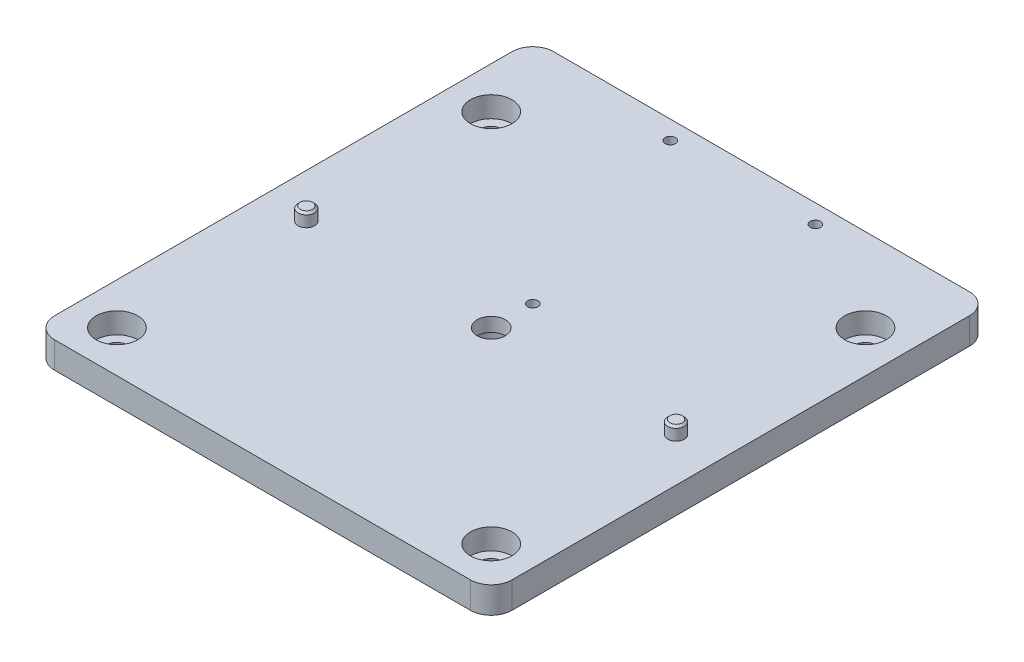
from build123d import *

# Parameters (mm, degrees)
BOSS_EXTRUDE1_DEPTH                              = 6.35
CBORE_FOR_1_4_SOCKET_HEAD_CAP_SCREW1_D           = 6.7564
CBORE_FOR_1_4_SOCKET_HEAD_CAP_SCREW1_CBORE_D     = 11.1125
CBORE_FOR_1_4_SOCKET_HEAD_CAP_SCREW1_CBORE_DEPTH = 2.999994
CBORE_FOR_M5_SHCS1_D                             = 5.5
CBORE_FOR_M5_SHCS1_DEPTH                         = 11.59
CBORE_FOR_M5_SHCS1_CBORE_D                       = 10
CBORE_FOR_M5_SHCS1_CBORE_DEPTH                   = 5
CBORE_FOR_M5_SHCS1_TIP                           = 1.652366702
F_1_8_0_125_PRESS_DOWEL_HOLE1_D                  = 3.96875
SKETCH12_W                                       = 110
SKETCH12_H                                       = 6.35
BOSS_EXTRUDE3_DEPTH                              = 10
FILLET1_R                                        = 5
M3X0_5_TAPPED_HOLE1_D                            = 2.5
SKETCH13_R                                       = 1.984375
BOSS_EXTRUDE4_DEPTH                              = 9.525
BOSS_EXTRUDE4_2_DEPTH                            = 9.525
CHAMFER1_SIZE                                    = 0.5
CHAMFER2_SIZE                                    = 0.5


with BuildPart() as part:
    # Sketch1 → Boss-Extrude1 (new body)
    with BuildSketch(Plane(origin=(0, 0, 0), x_dir=(1, 0, 0), z_dir=(0, 1, 0))):
        with BuildLine():
            Line((-50, -55), (50, -55))
            ThreePointArc((50, -55), (53.535533906, -53.535533906), (55, -50))
            Line((55, -50), (55, 55))
            Line((55, 55), (-55, 55))
            Line((-55, 55), (-55, -50))
            ThreePointArc((-55, -50), (-53.535533906, -53.535533906), (-50, -55))
        make_face()
    extrude(amount=BOSS_EXTRUDE1_DEPTH)

    # CBORE for 1/4 Socket Head Cap Screw1 (through all)
    with Locations(Plane(origin=(0, 0, 0), x_dir=(-1, 0, 0), z_dir=(0, -1, 0))):
        with Locations((0, 0)):
            CounterBoreHole(CBORE_FOR_1_4_SOCKET_HEAD_CAP_SCREW1_D / 2, CBORE_FOR_1_4_SOCKET_HEAD_CAP_SCREW1_CBORE_D / 2, CBORE_FOR_1_4_SOCKET_HEAD_CAP_SCREW1_CBORE_DEPTH)

    # CBORE for M5 SHCS1
    with Locations(Plane(origin=(0, 6.35, 0), x_dir=(1, 0, 0), z_dir=(0, 1, 0))):
        with Locations((45, 45), (45, -45), (-45, -45), (-45, 45)):
            CounterBoreHole(CBORE_FOR_M5_SHCS1_D / 2, CBORE_FOR_M5_SHCS1_CBORE_D / 2, CBORE_FOR_M5_SHCS1_CBORE_DEPTH, depth=CBORE_FOR_M5_SHCS1_DEPTH)
            with Locations((0, 0, -(CBORE_FOR_M5_SHCS1_DEPTH + CBORE_FOR_M5_SHCS1_TIP / 2))):  # 118° drill point
                Cone(0, CBORE_FOR_M5_SHCS1_D / 2, CBORE_FOR_M5_SHCS1_TIP, mode=Mode.SUBTRACT)

    # 1/8 (0.125) Press Dowel Hole1 (through all)
    with Locations(Plane(origin=(0, 6.35, 0), x_dir=(1, 0, 0), z_dir=(0, 1, 0))):
        with Locations((-44.45, 0), (44.45, 0)):
            Hole(F_1_8_0_125_PRESS_DOWEL_HOLE1_D / 2)

    # Sketch12 → Boss-Extrude3 (add)
    with BuildSketch(Plane(origin=(0, 0, -55), x_dir=(-1, 0, 0), z_dir=(0, 0, -1))):
        with Locations((0, 3.175)):
            Rectangle(SKETCH12_W, SKETCH12_H)
    extrude(amount=BOSS_EXTRUDE3_DEPTH)

    # Fillet1
    fillet1_edges = [part.edges().sort_by_distance(p)[0] for p in [
        (55, 3.175, -65),
        (-55, 3.175, -65),
    ]]
    fillet(fillet1_edges, radius=FILLET1_R)

    # M3x0.5 Tapped Hole1 (through all)
    with Locations(Plane(origin=(0, 0, 0), x_dir=(-1, 0, 0), z_dir=(0, -1, 0))):
        with Locations((-17.45, 60.5), (17.45, 60.5), (0, 10)):
            Hole(M3X0_5_TAPPED_HOLE1_D / 2)


with BuildPart() as body_2:
    # Sketch13 → Boss-Extrude4 (new body)
    with BuildSketch(Plane(origin=(0, 0, 0), x_dir=(1, 0, 0), z_dir=(0, 1, 0))):
        with Locations((44.45, 0)):
            Circle(SKETCH13_R)
    extrude(amount=BOSS_EXTRUDE4_DEPTH)

    # Chamfer1
    chamfer1_edges = [body_2.edges().sort_by_distance(p)[0] for p in [
        (42.465625, 0, 0),
        (42.465625, 9.525, 0),
    ]]
    chamfer(chamfer1_edges, length=CHAMFER1_SIZE)


with BuildPart() as body_3:
    # Sketch13 → Boss-Extrude4 2 (new body)
    with BuildSketch(Plane(origin=(0, 0, 0), x_dir=(1, 0, 0), z_dir=(0, 1, 0))):
        with Locations((-44.45, 0)):
            Circle(SKETCH13_R)
    extrude(amount=BOSS_EXTRUDE4_2_DEPTH)

    # Chamfer2
    chamfer2_edges = [body_3.edges().sort_by_distance(p)[0] for p in [
        (-46.434375, 0, 0),
        (-46.434375, 9.525, 0),
    ]]
    chamfer(chamfer2_edges, length=CHAMFER2_SIZE)


solid = Compound([part.part, body_2.part, body_3.part])
